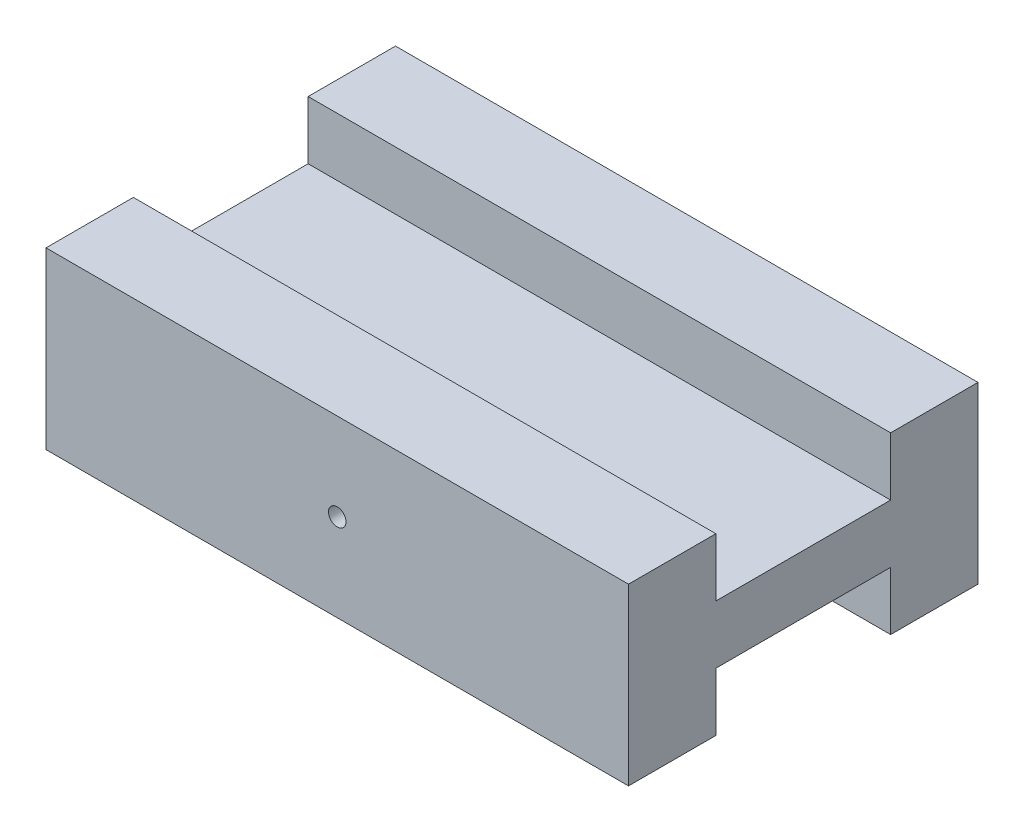
from build123d import *

# Parameters (mm, degrees)
SKETCH1_W           = 50
SKETCH1_H           = 30
BOSS_EXTRUDE1_DEPTH = 15
SKETCH2_W           = 50
SKETCH2_H           = 15
CUT_EXTRUDE1_DEPTH  = 5
SKETCH3_W           = 50
SKETCH3_H           = 15
CUT_EXTRUDE2_DEPTH  = 5
SKETCH4_R           = 0.75
CUT_EXTRUDE3_DEPTH  = 30


with BuildPart() as part:
    # Sketch1 → Boss-Extrude1 (new body)
    with BuildSketch(Plane(origin=(0, 0, 0), x_dir=(1, 0, 0), z_dir=(0, 1, 0))):
        with Locations((25, 15)):
            Rectangle(SKETCH1_W, SKETCH1_H)
    extrude(amount=BOSS_EXTRUDE1_DEPTH)

    # Sketch2 → Cut-Extrude1 (cut)
    with BuildSketch(Plane(origin=(0, 15, 0), x_dir=(1, 0, 0), z_dir=(0, 1, 0))):
        with Locations((25, 15)):
            Rectangle(SKETCH2_W, SKETCH2_H)
    extrude(amount=-CUT_EXTRUDE1_DEPTH, mode=Mode.SUBTRACT)

    # Sketch3 → Cut-Extrude2 (cut)
    with BuildSketch(Plane.XZ):
        with Locations((25, -15)):
            Rectangle(SKETCH3_W, SKETCH3_H)
    extrude(amount=-CUT_EXTRUDE2_DEPTH, mode=Mode.SUBTRACT)

    # Sketch4 → Cut-Extrude3 (cut)
    with BuildSketch(Plane.XY):
        with Locations((25, 7.5)):
            Circle(SKETCH4_R)
    extrude(amount=-CUT_EXTRUDE3_DEPTH, mode=Mode.SUBTRACT)


solid = part.part
